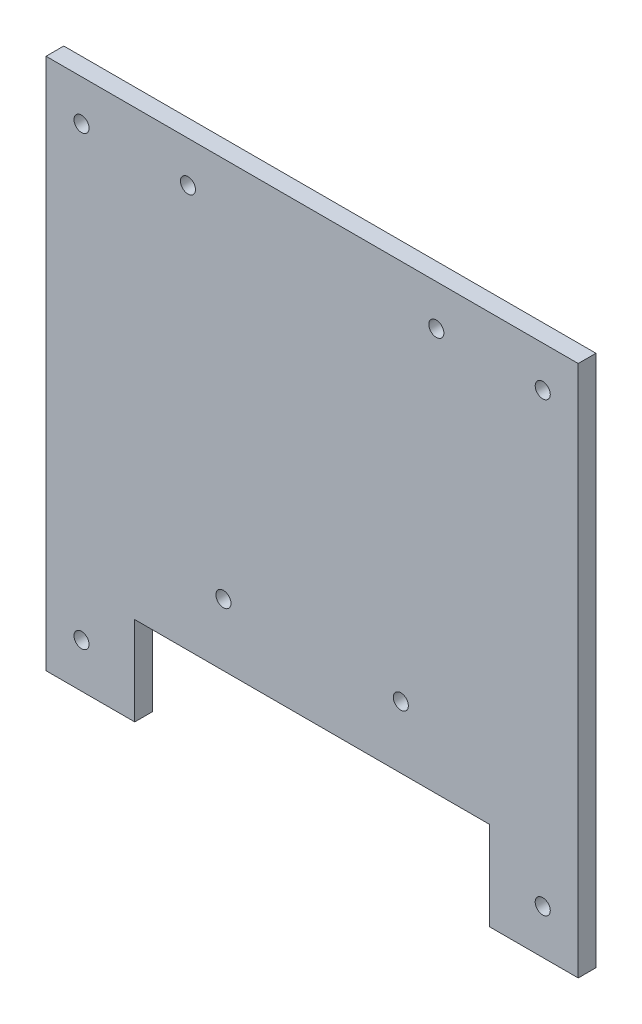
from build123d import *

# Parameters (mm, degrees)
SALIENTE_EXTRUIR1_DEPTH = 10
CROQUIS2_R              = 4.25
CORTAR_EXTRUIR1_DEPTH   = 11
CROQUIS3_R              = 4.25
CORTAR_EXTRUIR2_DEPTH   = 11


with BuildPart() as part:
    # Croquis1 → Saliente-Extruir1 (new body)
    with BuildSketch(Plane.XY):
        Polygon((-300, 0), (-250, 0), (-250, 50), (-50, 50), (-50, 0), (0, 0), (0, 300), (-300, 300), align=None)
    extrude(amount=SALIENTE_EXTRUIR1_DEPTH)

    # Croquis2 → Cortar-Extruir1 (cut, through all)
    with BuildSketch(Plane.XY.offset(10)):
        with Locations((-280, 25)):
            Circle(CROQUIS2_R)
        with Locations((-280, 277)):
            Circle(CROQUIS2_R)
        with Locations((-80, 277)):
            Circle(CROQUIS2_R)
        with Locations((-220, 277)):
            Circle(CROQUIS2_R)
        with Locations((-20, 277)):
            Circle(CROQUIS2_R)
        with Locations((-20, 25)):
            Circle(CROQUIS2_R)
        with Locations((120, 277)):
            Circle(CROQUIS2_R)
        with Locations((-420, 277)):
            Circle(CROQUIS2_R)
    extrude(amount=-CORTAR_EXTRUIR1_DEPTH, mode=Mode.SUBTRACT)

    # Croquis3 → Cortar-Extruir2 (cut, through all)
    with BuildSketch(Plane.XY.offset(10)):
        with Locations((-100, 85)):
            Circle(CROQUIS3_R)
        with Locations((-350, 85)):
            Circle(CROQUIS3_R)
        with Locations((-475, 85)):
            Circle(CROQUIS3_R)
        with Locations((50, 85)):
            Circle(CROQUIS3_R)
        with Locations((-200, 85)):
            Circle(CROQUIS3_R)
    extrude(amount=-CORTAR_EXTRUIR2_DEPTH, mode=Mode.SUBTRACT)


solid = part.part
